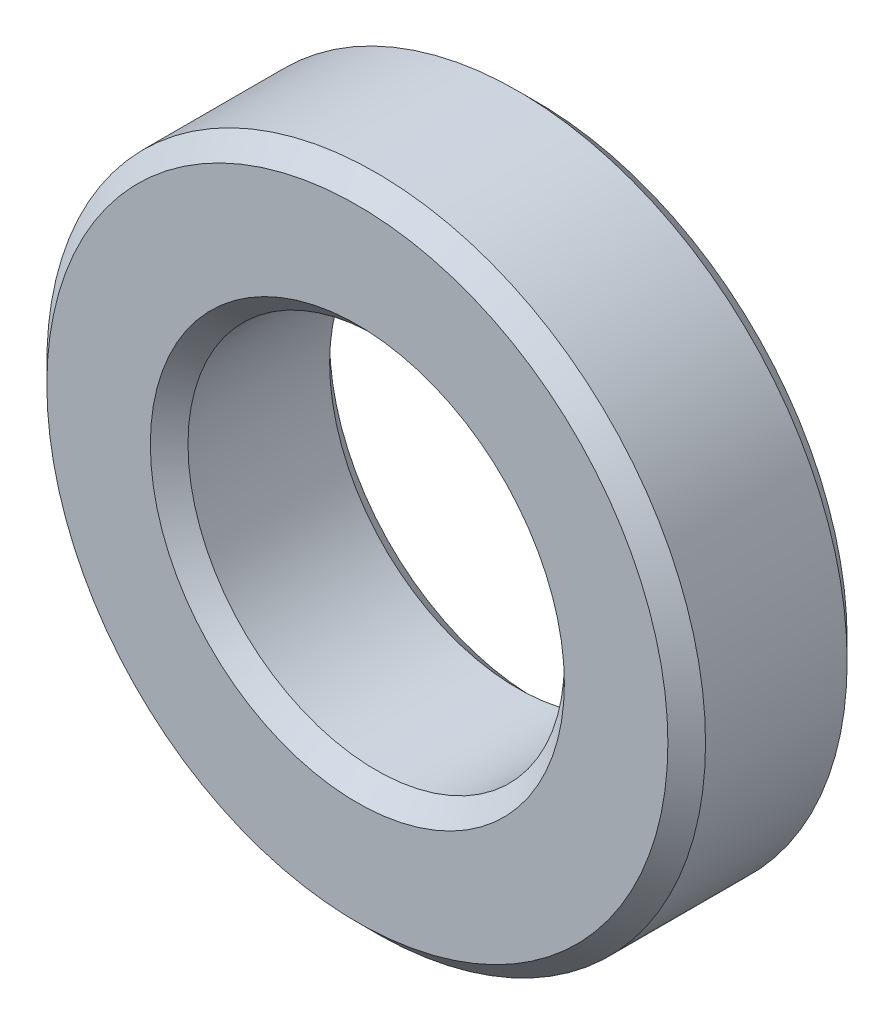
from build123d import *

# Parameters (mm, degrees)
ESBO_O1_R                = 17.5
ESBO_O1_R_2              = 10
RESSALTO_EXTRUS_O1_DEPTH = 9.525
CHANFRO1_SIZE            = 1


with BuildPart() as part:
    # Esboço1 → Ressalto-extrusão1 (new body)
    with BuildSketch(Plane.XY):
        Circle(ESBO_O1_R)
        Circle(ESBO_O1_R_2, mode=Mode.SUBTRACT)
    extrude(amount=RESSALTO_EXTRUS_O1_DEPTH)

    # Chanfro1
    chanfro1_edges = [part.edges().sort_by_distance(p)[0] for p in [
        (-17.5, 0, 0),
        (-17.5, 0, 9.525),
        (-10, 0, 0),
        (-10, 0, 9.525),
    ]]
    chamfer(chanfro1_edges, length=CHANFRO1_SIZE)


solid = part.part
